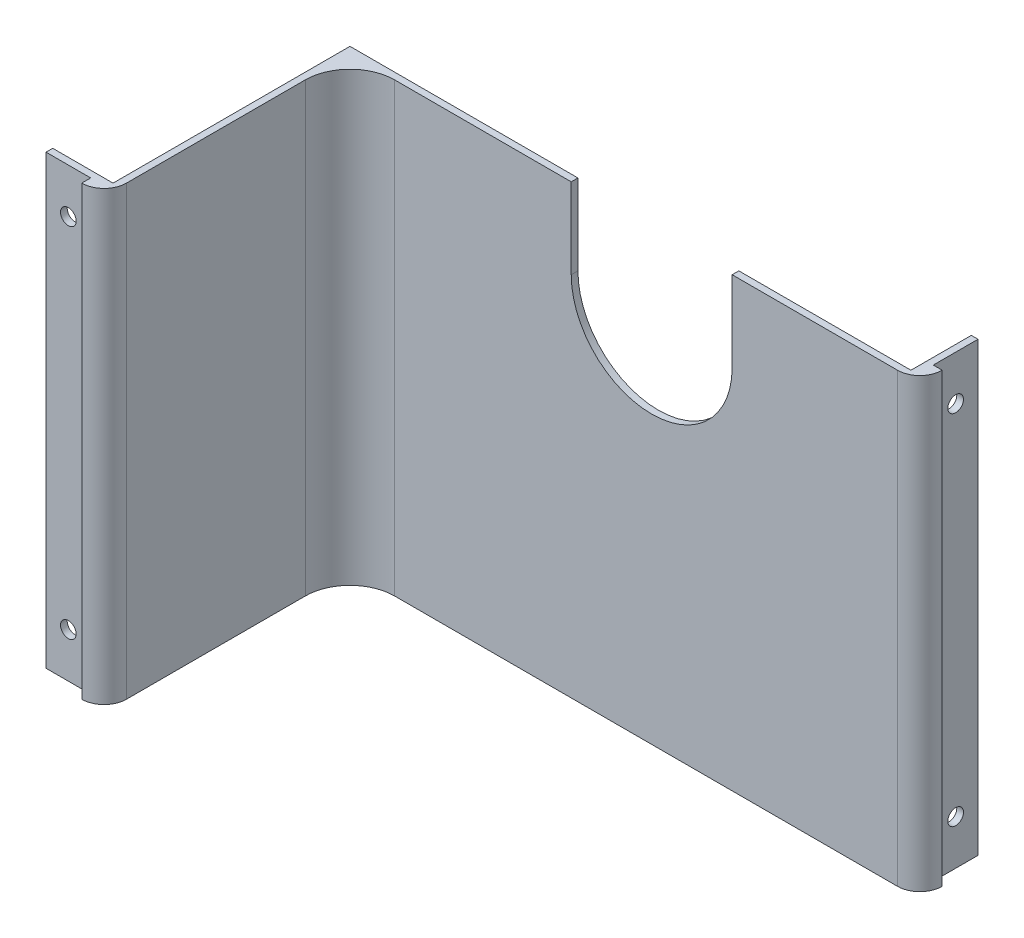
from build123d import *

# Parameters (mm, degrees)
EXTRUDE_1_DEPTH     = 100
CUT_EXTRUDE_1_DEPTH = 10
SKETCH_3_R          = 1.75
CUT_EXTRUDE_2_DEPTH = 10
SKETCH_4_R          = 1.75
CUT_EXTRUDE_3_DEPTH = 10


with BuildPart() as part:
    # Эскиз1 → Бобышка-Вытянуть1 (new body)
    with BuildSketch(Plane(origin=(0, 0, 0), x_dir=(1, 0, 0), z_dir=(0, 1, 0))):
        with BuildLine():
            Line((0, 0), (-112.5, 0))
            ThreePointArc((-112.5, 0), (-119.571067812, -2.928932188), (-122.5, -10))
            Line((-122.5, -10), (-122.5, -50))
            ThreePointArc((-122.5, -50), (-123.964466094, -53.535533906), (-127.5, -55))
            Line((-127.5, -55), (-127.5, -53))
            Line((-127.5, -53), (-137.5, -53))
            Line((-137.5, -53), (-137.5, -51.5))
            Line((-137.5, -51.5), (-124, -51.5))
            Line((-124, -51.5), (-124, 1.5))
            Line((-124, 1.5), (1.5, 1.5))
            Line((1.5, 1.5), (1.5, 15))
            Line((1.5, 15), (3, 15))
            Line((3, 15), (3, 5))
            Line((3, 5), (5, 5))
            ThreePointArc((5, 5), (3.535533906, 1.464466094), (0, 0))
        make_face()
    extrude(amount=EXTRUDE_1_DEPTH)

    # Эскиз2 → Вырез-Вытянуть1 (cut)
    with BuildSketch(Plane.XY):
        with BuildLine():
            Line((-73, 100), (-37, 100))
            Line((-37, 100), (-37, 82.000001723))
            ThreePointArc((-37, 82.000001723), (-54.999999139, 64.000000861), (-73, 82))
            Line((-73, 82), (-73, 100))
        make_face()
    extrude(amount=-CUT_EXTRUDE_1_DEPTH, mode=Mode.SUBTRACT)

    # Эскиз3 → Вырез-Вытянуть2 (cut)
    with BuildSketch(Plane(origin=(3, 0, 0), x_dir=(0, 0, -1), z_dir=(1, 0, 0))):
        with Locations((10, 90)):
            Circle(SKETCH_3_R)
        with Locations((10, 10)):
            Circle(SKETCH_3_R)
    extrude(amount=-CUT_EXTRUDE_2_DEPTH, mode=Mode.SUBTRACT)

    # Эскиз4 → Вырез-Вытянуть3 (cut)
    with BuildSketch(Plane.XY.offset(53)):
        with Locations((-132.5, 90)):
            Circle(SKETCH_4_R)
        with Locations((-132.5, 10)):
            Circle(SKETCH_4_R)
    extrude(amount=-CUT_EXTRUDE_3_DEPTH, mode=Mode.SUBTRACT)


solid = part.part
